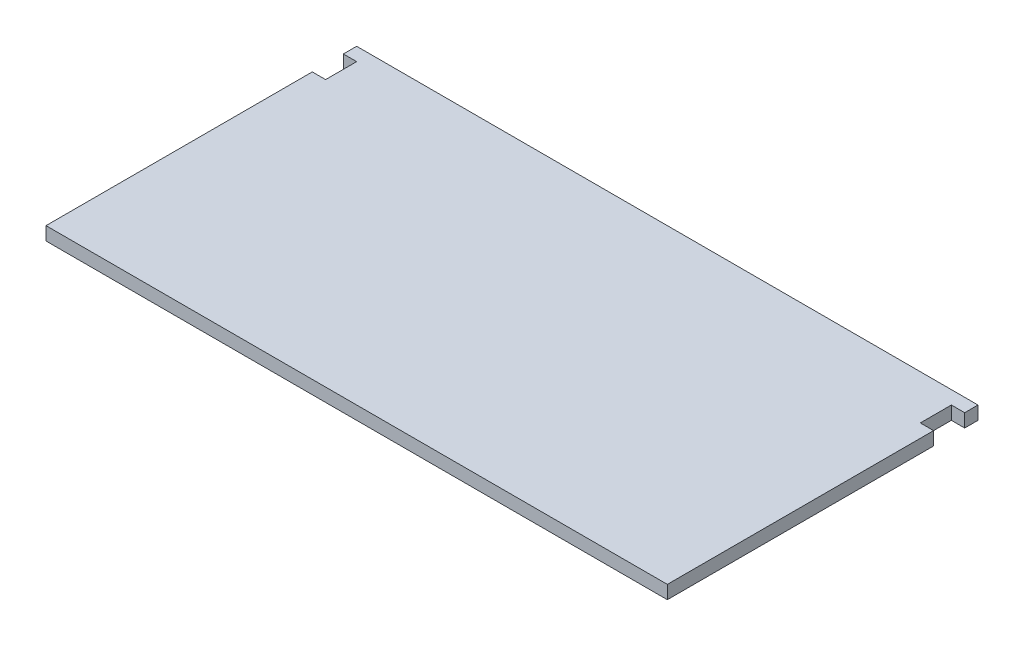
from build123d import *

# Parameters (mm, degrees)
SKETCH1_W           = 140
SKETCH1_H           = 70
BOSS_EXTRUDE1_DEPTH = 3
SKETCH2_W           = 3
SKETCH2_H           = 7
CUT_EXTRUDE1_DEPTH  = 3


with BuildPart() as part:
    # Sketch1 → Boss-Extrude1 (new body)
    with BuildSketch(Plane(origin=(0, 0, 0), x_dir=(1, 0, 0), z_dir=(0, 1, 0))):
        Rectangle(SKETCH1_W, SKETCH1_H)
    extrude(amount=BOSS_EXTRUDE1_DEPTH)

    # Sketch2 → Cut-Extrude1 (cut)
    with BuildSketch(Plane(origin=(0, 3, 0), x_dir=(1, 0, 0), z_dir=(0, 1, 0))):
        with Locations((-68.5, 28.5)):
            Rectangle(SKETCH2_W, SKETCH2_H)
        with Locations((68.5, 28.5)):
            Rectangle(SKETCH2_W, SKETCH2_H)
    extrude(amount=-CUT_EXTRUDE1_DEPTH, mode=Mode.SUBTRACT)


solid = part.part
